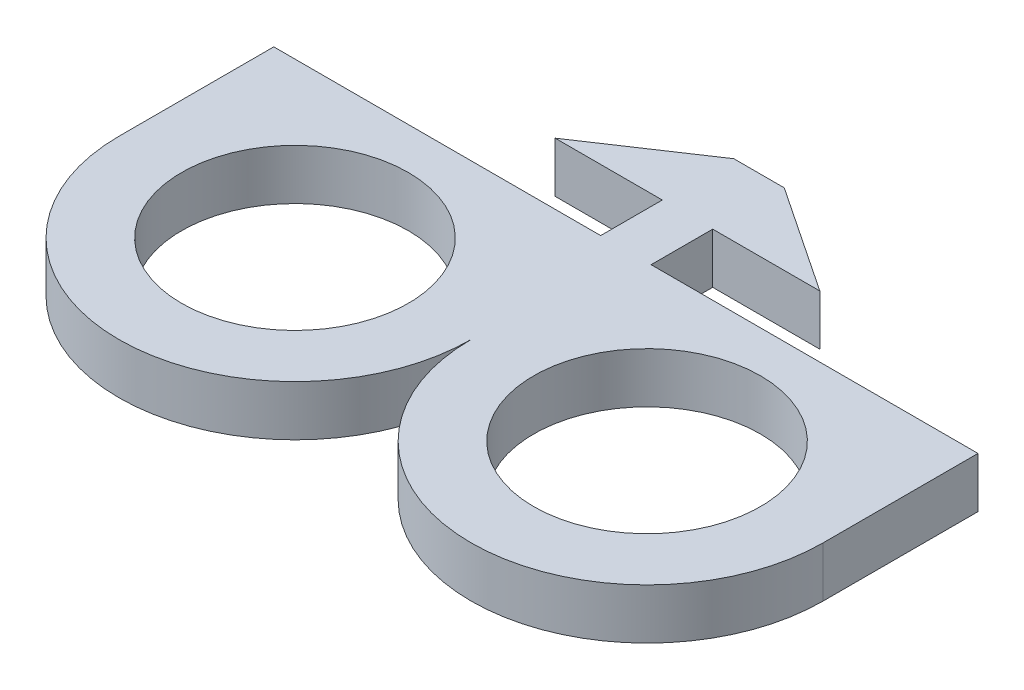
from build123d import *

# Parameters (mm, degrees)
BOSS_EXTRUDE1_DEPTH = 3.5814
BOSS_EXTRUDE2_DEPTH = 3.5814
SKETCH4_R           = 8.0518
CUT_EXTRUDE2_DEPTH  = 4.5814


with BuildPart() as part:
    # Sketch1 → Boss-Extrude1 (new body)
    with BuildSketch(Plane(origin=(0, 0, 0), x_dir=(1, 0, 0), z_dir=(0, 1, 0))):
        Polygon((-25.0063, -13.1856988), (25.0063, -13.1856988), (25.0063, -2.1874988), (1.7907, -2.1874988), (1.7907, 2.1874988), (9.398, 2.1874988), (1.7907, 7.2674988), (-1.7907, 7.2674988), (-9.398, 2.1874988), (-1.7907, 2.1874988), (-1.7907, -2.1874988), (-25.0063, -2.1874988), align=None)
    extrude(amount=BOSS_EXTRUDE1_DEPTH)

    # Sketch3 → Boss-Extrude2 (add)
    with BuildSketch(Plane(origin=(0, 3.5814, 0), x_dir=(1, 0, 0), z_dir=(0, 1, 0))):
        with BuildLine():
            Line((0, -13.1856988), (-25.0063, -13.1856988))
            ThreePointArc((-25.0063, -13.1856988), (-12.50315, -25.6888488), (0, -13.1856988))
        make_face()
        with BuildLine():
            Line((25.0063, -13.1856988), (0, -13.1856988))
            ThreePointArc((0, -13.1856988), (12.50315, -25.6888488), (25.0063, -13.1856988))
        make_face()
    extrude(amount=-BOSS_EXTRUDE2_DEPTH)

    # Sketch4 → Cut-Extrude2 (cut, through all)
    with BuildSketch(Plane(origin=(0, 3.5814, 0), x_dir=(1, 0, 0), z_dir=(0, 1, 0))):
        with Locations((-12.50315, -13.1856988)):
            Circle(SKETCH4_R)
        with Locations((12.50315, -13.1856988)):
            Circle(SKETCH4_R)
    extrude(amount=-CUT_EXTRUDE2_DEPTH, mode=Mode.SUBTRACT)


solid = part.part
